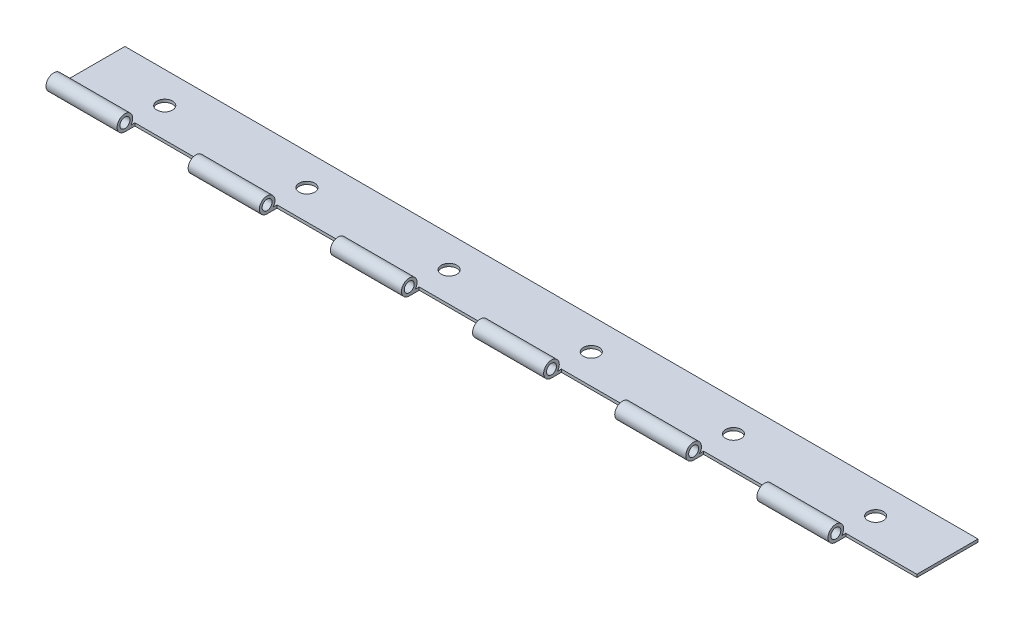
from build123d import *

# Parameters (mm, degrees)
SKETCH1_R           = 1.778
BOSS_EXTRUDE1_DEPTH = 152.4
SKETCH2_R           = 2.794
SKETCH2_W           = 25.4
SKETCH2_H           = 6.35
CUT_EXTRUDE1_DEPTH  = 914.4
LPATTERN1_COUNT     = 4
LPATTERN1_PITCH     = 50.8
LPATTERN2_COUNT     = 4
LPATTERN2_PITCH     = 50.8


with BuildPart() as part:
    # Sketch1 → Boss-Extrude1 (new body, symmetric)
    with BuildSketch(Plane(origin=(0, 0, 0), x_dir=(0, 0, -1), z_dir=(1, 0, 0))):
        with BuildLine():
            Line((0, -2.794), (25.4, -2.794))
            Line((25.4, -2.794), (25.4, -1.778))
            Line((25.4, -1.778), (2.155261469, -1.778))
            ThreePointArc((2.155261469, -1.778), (-1.191365603, 2.52726809), (0, -2.794))
        make_face()
        Circle(SKETCH1_R, mode=Mode.SUBTRACT)
    extrude(amount=BOSS_EXTRUDE1_DEPTH, both=True)

    # Sketch2 → Cut-Extrude1 (cut, symmetric)
    with BuildSketch(Plane(origin=(0, -1.778, 0), x_dir=(1, 0, 0), z_dir=(0, 1, 0))):
        with Locations((-25.4, 14.224)):
            Circle(SKETCH2_R)
        with Locations((-12.7, 0.381)):
            Rectangle(SKETCH2_W, SKETCH2_H)
    cut_extrude1 = extrude(amount=CUT_EXTRUDE1_DEPTH, both=True, mode=Mode.SUBTRACT)

    # LPattern1: Cut-Extrude1 ×4
    with Locations(*[(-i * LPATTERN1_PITCH, 0, 0) for i in range(1, LPATTERN1_COUNT)]):
        add(cut_extrude1, mode=Mode.SUBTRACT)

    # LPattern2: Cut-Extrude1 ×4
    with Locations(*[(i * LPATTERN2_PITCH, 0, 0) for i in range(1, LPATTERN2_COUNT)]):
        add(cut_extrude1, mode=Mode.SUBTRACT)


solid = part.part
